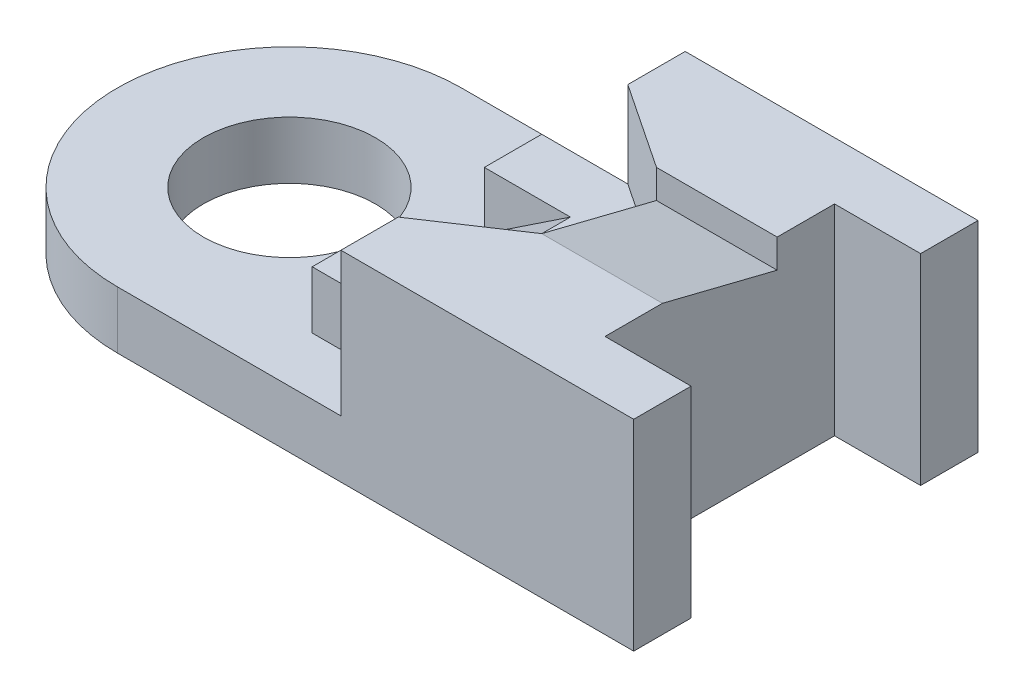
from build123d import *

# Parameters (mm, degrees)
SKETCH1_R           = 3
BOSS_EXTRUDE1_DEPTH = 2
BOSS_EXTRUDE2_DEPTH = 2
CUT_EXTRUDE1_DEPTH  = 2
BOSS_EXTRUDE3_DEPTH = 3
CUT_EXTRUDE2_DEPTH  = 13


with BuildPart() as part:
    # Sketch1 → Boss-Extrude1 (new body)
    with BuildSketch(Plane(origin=(0, 0, 0), x_dir=(1, 0, 0), z_dir=(0, 1, 0))):
        with BuildLine():
            Line((9, 4), (9, 6))
            Line((9, 6), (-9, 6))
            ThreePointArc((-9, 6), (-15, 0), (-9, -6))
            Line((-9, -6), (9, -6))
            Line((9, -6), (9, -4))
            Line((9, -4), (6, -4))
            Line((6, -4), (6, 4))
            Line((6, 4), (9, 4))
        make_face()
        with Locations((-9, 0)):
            Circle(SKETCH1_R, mode=Mode.SUBTRACT)
    extrude(amount=BOSS_EXTRUDE1_DEPTH)

    # Sketch2 → Boss-Extrude2 (add)
    with BuildSketch(Plane(origin=(0, 2, 0), x_dir=(1, 0, 0), z_dir=(0, 1, 0))):
        Polygon((9, 6), (-1.205687829, 6), (-1.205687829, 4), (-4.205687829, 4), (-4.205687829, -4), (-1.205687829, -4), (-1.205687829, -6), (9, -6), (9, -4), (6, -4), (6, 4), (9, 4), align=None)
    extrude(amount=BOSS_EXTRUDE2_DEPTH)

    # Sketch3 → Cut-Extrude1 (cut, symmetric)
    with BuildSketch(Plane.XY):
        Polygon((-1.205687829, 4), (-4.205687829, 2), (-4.205687829, 4), align=None)
    extrude(amount=CUT_EXTRUDE1_DEPTH, both=True, mode=Mode.SUBTRACT)

    # Sketch4 → Boss-Extrude3 (add)
    with BuildSketch(Plane(origin=(0, 4, 0), x_dir=(1, 0, 0), z_dir=(0, 1, 0))):
        Polygon((9, 6), (-1.205687829, 6), (-1.205687829, 4), (1.794312171, 2), (1.794312171, -2), (-1.205687829, -4), (-1.205687829, -6), (9, -6), (9, -4), (6, -4), (6, 4), (9, 4), align=None)
    extrude(amount=BOSS_EXTRUDE3_DEPTH)

    # Sketch5 → Cut-Extrude2 (cut)
    with BuildSketch(Plane(origin=(6, 0, 0), x_dir=(0, 0, -1), z_dir=(1, 0, 0))):
        Polygon((2, 7), (2, 6), (-2, 7), align=None)
    extrude(amount=-CUT_EXTRUDE2_DEPTH, mode=Mode.SUBTRACT)


solid = part.part
